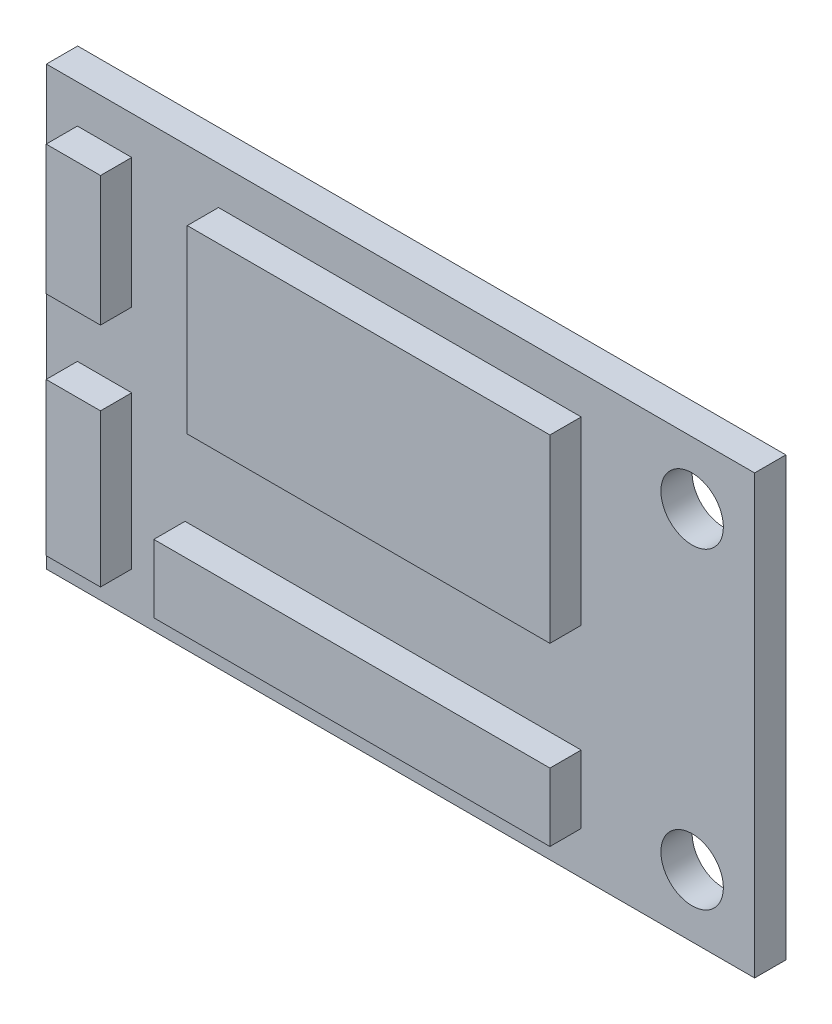
from build123d import *

# Parameters (mm, degrees)
SKETCH_1_W      = 34
SKETCH_1_H      = 21
SKETCH_1_R      = 1.5
EXTRUDE_1_DEPTH = 1.5
SKETCH_2_W      = 2.609332225
SKETCH_2_H      = 6.222253767
SKETCH_2_H_2    = 7.326202017
SKETCH_2_W_2    = 17.412274655
SKETCH_2_H_3    = 8.664478865
SKETCH_2_W_3    = 19.018017562
SKETCH_2_H_4    = 3.261665282
EXTRUDE_2_DEPTH = 1.5


with BuildPart() as part:
    # 草图1 → 凸台-拉伸1 (new body)
    with BuildSketch(Plane.XY):
        Rectangle(SKETCH_1_W, SKETCH_1_H)
        with Locations((14, 7.5)):
            Circle(SKETCH_1_R, mode=Mode.SUBTRACT)
        with Locations((14, -7.5)):
            Circle(SKETCH_1_R, mode=Mode.SUBTRACT)
    extrude(amount=EXTRUDE_1_DEPTH)

    # 草图2 → 凸台-拉伸2 (add)
    with BuildSketch(Plane.XY.offset(1.5)):
        with Locations((-14.208471454, 5.553351982)):
            Rectangle(SKETCH_2_W, SKETCH_2_H)
        with Locations((-14.208471454, -4.783617987)):
            Rectangle(SKETCH_2_W, SKETCH_2_H_2)
        with Locations((-0.032772348, 4.332239433)):
            Rectangle(SKETCH_2_W_2, SKETCH_2_H_3)
        with Locations((-0.835643802, -6.815886354)):
            Rectangle(SKETCH_2_W_3, SKETCH_2_H_4)
    extrude(amount=EXTRUDE_2_DEPTH)


solid = part.part
